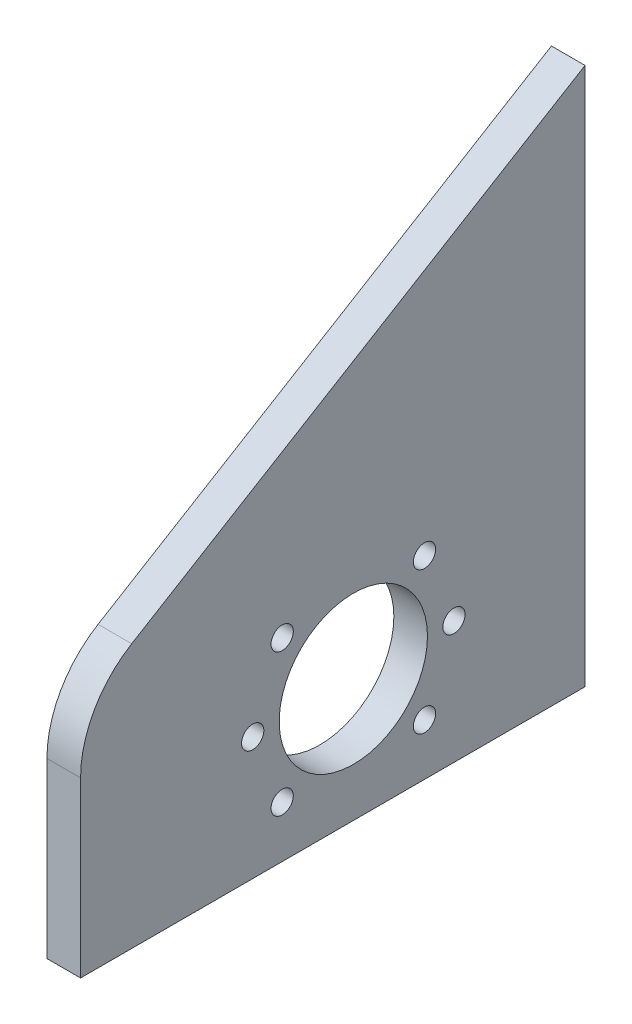
from build123d import *

# Parameters (mm, degrees)
BOSS_EXTRUDE1_DEPTH = 6.35
FILLET1_R           = 20
SKETCH2_R           = 14
CUT_EXTRUDE1_DEPTH  = 6.35
SKETCH3_R           = 2.1
CUT_EXTRUDE2_DEPTH  = 10


with BuildPart() as part:
    # Sketch1 → Boss-Extrude1 (new body)
    with BuildSketch(Plane(origin=(0, 0, 0), x_dir=(0, 0, -1), z_dir=(1, 0, 0))):
        Polygon((0, 0), (-95.25, 0), (-95.25, 44), (0, 101.6), align=None)
    extrude(amount=-BOSS_EXTRUDE1_DEPTH)

    # Fillet1
    fillet1_edges = [part.edges().sort_by_distance(p)[0] for p in [
        (-3.175, 44, 95.25),
    ]]
    fillet(fillet1_edges, radius=FILLET1_R)

    # Sketch2 → Cut-Extrude1 (cut)
    with BuildSketch(Plane(origin=(0, 0, 0), x_dir=(0, 0, -1), z_dir=(1, 0, 0))):
        with Locations((-43.75, 23.17)):
            Circle(SKETCH2_R)
    extrude(amount=-CUT_EXTRUDE1_DEPTH, mode=Mode.SUBTRACT)

    # Sketch3 → Cut-Extrude2 (cut)
    with BuildSketch(Plane(origin=(0, 0, 0), x_dir=(0, 0, -1), z_dir=(1, 0, 0))):
        with Locations((-57.185028843, 36.605028843)):
            Circle(SKETCH3_R)
        with Locations((-62.75, 23.17)):
            Circle(SKETCH3_R)
        with Locations((-57.185028843, 9.734971157)):
            Circle(SKETCH3_R)
        with Locations((-30.314971157, 9.734971157)):
            Circle(SKETCH3_R)
        with Locations((-24.75, 23.17)):
            Circle(SKETCH3_R)
        with Locations((-30.314971157, 36.605028843)):
            Circle(SKETCH3_R)
    extrude(amount=-CUT_EXTRUDE2_DEPTH, mode=Mode.SUBTRACT)


solid = part.part
